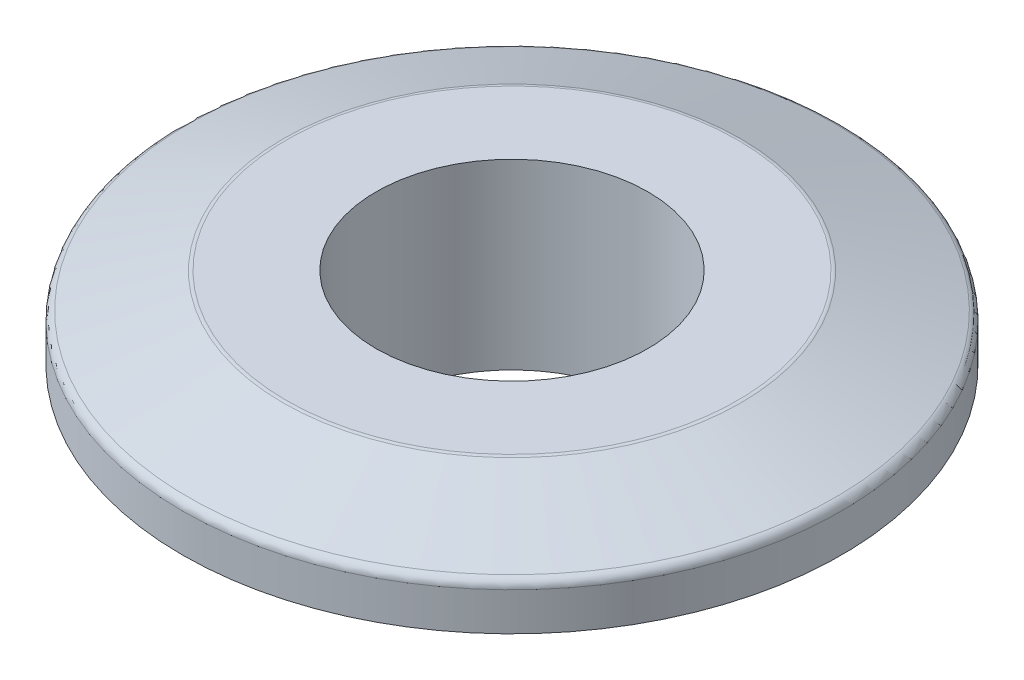
from build123d import *

# Parameters (mm, degrees)
SKETCH1_R           = 22.479
SKETCH1_R_2         = 9.271
BOSS_EXTRUDE1_DEPTH = 12.446
SKETCH2_R           = 22.479
SKETCH2_R_2         = 12.7
CUT_EXTRUDE1_DEPTH  = 6.858
CHAMFER1_SIZE       = 2.54
CHAMFER1_SIZE2      = 6.978592645
CHAMFER2_SIZE       = 0.635
FILLET1_R           = 0.635


with BuildPart() as part:
    # Sketch1 → Boss-Extrude1 (new body)
    with BuildSketch(Plane(origin=(0, 0, 0), x_dir=(1, 0, 0), z_dir=(0, 1, 0))):
        Circle(SKETCH1_R)
        Circle(SKETCH1_R_2, mode=Mode.SUBTRACT)
    extrude(amount=BOSS_EXTRUDE1_DEPTH)

    # Sketch2 → Cut-Extrude1 (cut)
    with BuildSketch(Plane.XZ):
        Circle(SKETCH2_R)
        Circle(SKETCH2_R_2, mode=Mode.SUBTRACT)
    extrude(amount=-CUT_EXTRUDE1_DEPTH, mode=Mode.SUBTRACT)

    # Chamfer1
    chamfer1_edges = [part.edges().sort_by_distance(p)[0] for p in [
        (-22.479, 12.446, 0),
    ]]
    chamfer1_side = [part.faces().sort_by_distance(p)[0] for p in [
        (-22.479, 9.652, 0),
    ]]
    chamfer(chamfer1_edges, length=CHAMFER1_SIZE, length2=CHAMFER1_SIZE2, reference=chamfer1_side[0])

    # Chamfer2
    chamfer2_edges = [part.edges().sort_by_distance(p)[0] for p in [
        (-12.7, 0, 0),
    ]]
    chamfer(chamfer2_edges, length=CHAMFER2_SIZE)

    # Fillet1
    fillet1_edges = [part.edges().sort_by_distance(p)[0] for p in [
        (-15.500407355, 12.446, 0),
        (-22.479, 9.906, 0),
    ]]
    fillet(fillet1_edges, radius=FILLET1_R)


solid = part.part
